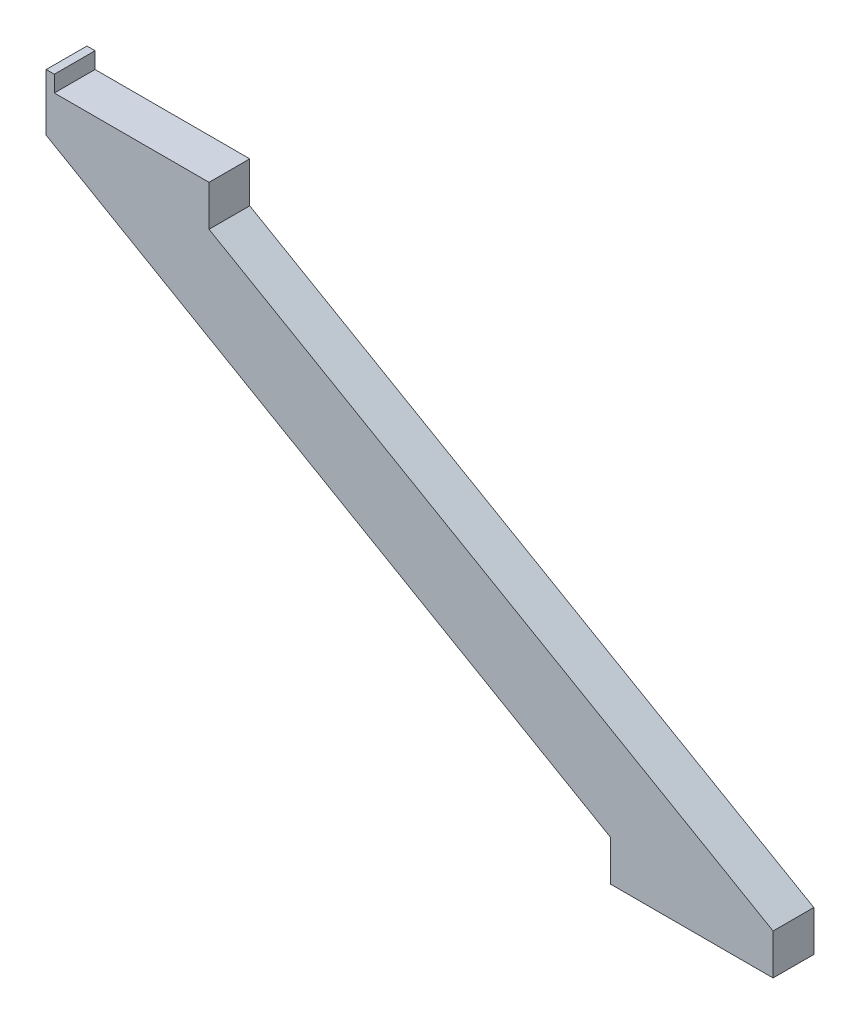
from build123d import *

# Parameters (mm, degrees)
BOSS_EXTRUDE1_DEPTH = 25
SKETCH2_W           = 5
SKETCH2_H           = 25
BOSS_EXTRUDE2_DEPTH = 10


with BuildPart() as part:
    # Sketch1 → Boss-Extrude1 (new body)
    with BuildSketch(Plane.XY):
        Polygon((0, 0), (100, 0), (100, -25), (446.410161514, -225), (446.410161514, -250), (346.410161514, -250), (346.410161514, -225), (0, -25), align=None)
    extrude(amount=BOSS_EXTRUDE1_DEPTH)

    # Sketch2 → Boss-Extrude2 (add)
    with BuildSketch(Plane(origin=(0, 0, 0), x_dir=(1, 0, 0), z_dir=(0, 1, 0))):
        with Locations((2.5, -12.5)):
            Rectangle(SKETCH2_W, SKETCH2_H)
    extrude(amount=BOSS_EXTRUDE2_DEPTH)


solid = part.part
